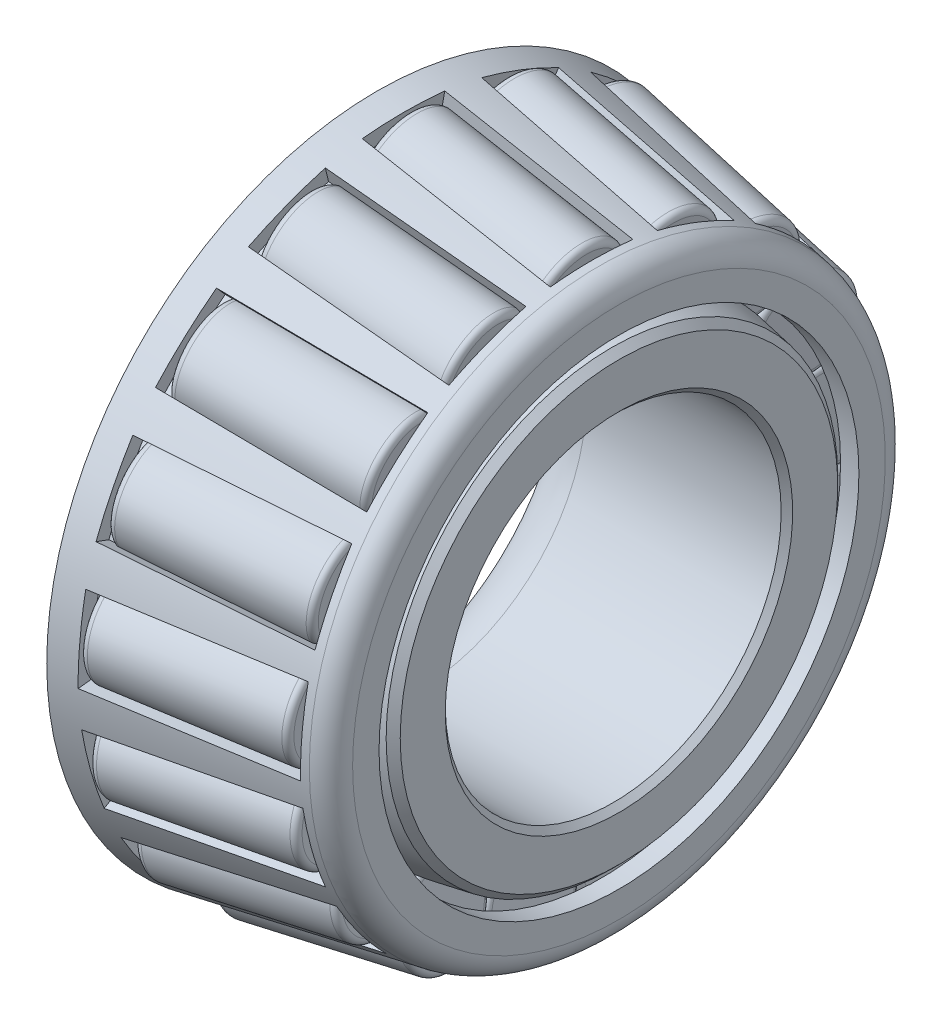
from build123d import *
from OCP.BRepFilletAPI import BRepFilletAPI_MakeChamfer

# Parameters (mm, degrees)
EXTRUDE2_DEPTH    = 2.7305
CIRPATTERN1_COUNT = 17
FILLET1_R         = 0.4064
CIRPATTERN2_COUNT = 17
CHAMFER1_SIZE     = 0.381
CHAMFER1_SIZE2    = 0.473301055
CHAMFER1_SIZE2_2  = 0.327669961


with BuildPart() as part:
    # Sketch1 → Revolve1 (revolve)
    with BuildSketch(Plane.XY):
        with BuildLine():
            Line((-1.651, 21.856453394), (13.047480633, 19.18400237))
            ThreePointArc((13.047480633, 19.18400237), (13.982305872, 18.639295448), (14.351, 17.622108888))
            Line((14.351, 17.622108888), (14.351, 15.875))
            Line((14.351, 15.875), (13.137628204, 15.875))
            Line((13.137628204, 15.875), (13.137628204, 17.625667396))
            ThreePointArc((13.137628204, 17.625667396), (13.04619206, 17.877929663), (12.814355401, 18.01301698))
            Line((12.814355401, 18.01301698), (-1.651, 20.643081598))
            Line((-1.651, 20.643081598), (-1.651, 21.856453394))
        make_face()
    revolve(axis=Axis((0, 0, 0), (1, 0, 0)))

    # Sketch2 → Extrude2 (cut, symmetric)
    with BuildSketch(Plane.XY):
        Polygon((0.786251435, 25.156697843), (13.231418702, 22.893940158), (12.09549617, 16.646366229), (-0.349671097, 18.909123914), align=None)
    extrude2 = extrude(amount=EXTRUDE2_DEPTH, both=True, mode=Mode.SUBTRACT)

    # CirPattern1: Extrude2 ×17 about axis
    cirpattern1_axis = Axis((-1.651, 0, 0), (1, 0, 0))
    for i in range(1, CIRPATTERN1_COUNT):
        add(extrude2.rotate(cirpattern1_axis, i * 360 / CIRPATTERN1_COUNT), mode=Mode.SUBTRACT)


with BuildPart() as body_2:
    # Sketch1_5 → Revolve2 (revolve)
    with BuildSketch(Plane.XY):
        with BuildLine():
            Line((14.351, 14.853227273), (-2.794, 17.9705))
            Line((-2.794, 17.9705), (-2.794, 14.986))
            ThreePointArc((-2.794, 14.986), (-1.659478117, 12.247021883), (1.0795, 11.1125))
            Line((1.0795, 11.1125), (14.351, 11.1125))
            Line((14.351, 11.1125), (14.351, 14.853227273))
        make_face()
    revolve(axis=Axis((0, 0, 0), (1, 0, 0)))


with BuildPart() as body_3:
    # Sketch3 → Revolve3 (revolve)
    with BuildSketch(Plane.XY):
        Polygon((0.025183339, 18.840968562), (11.720641734, 16.714521581), (12.288603, 19.838308545), (0.593144605, 21.964755526), align=None)
    revolve(axis=Axis((0.025183339, 18.840968562, 0), (0.9838699100999075, -0.17888543819998284, 0)))

    # Fillet1
    fillet1_edges = [body_3.edges().sort_by_distance(p)[0] for p in [
        (11.152680468, 13.590734616, 0),
        (-0.542777928, 15.717181597, 0),
    ]]
    fillet(fillet1_edges, radius=FILLET1_R)


with BuildPart() as cirpattern2_1:
    # CirPattern2: pattern copy
    add(body_3.part.rotate(Axis((0, 0, 0), (-1, 0, 0)), 1 * 360 / CIRPATTERN2_COUNT))


with BuildPart() as cirpattern2_2:
    # CirPattern2: pattern copy
    add(body_3.part.rotate(Axis((0, 0, 0), (-1, 0, 0)), 2 * 360 / CIRPATTERN2_COUNT))


with BuildPart() as cirpattern2_3:
    # CirPattern2: pattern copy
    add(body_3.part.rotate(Axis((0, 0, 0), (-1, 0, 0)), 3 * 360 / CIRPATTERN2_COUNT))


with BuildPart() as cirpattern2_4:
    # CirPattern2: pattern copy
    add(body_3.part.rotate(Axis((0, 0, 0), (-1, 0, 0)), 4 * 360 / CIRPATTERN2_COUNT))


with BuildPart() as cirpattern2_5:
    # CirPattern2: pattern copy
    add(body_3.part.rotate(Axis((0, 0, 0), (-1, 0, 0)), 5 * 360 / CIRPATTERN2_COUNT))


with BuildPart() as cirpattern2_6:
    # CirPattern2: pattern copy
    add(body_3.part.rotate(Axis((0, 0, 0), (-1, 0, 0)), 6 * 360 / CIRPATTERN2_COUNT))


with BuildPart() as cirpattern2_7:
    # CirPattern2: pattern copy
    add(body_3.part.rotate(Axis((0, 0, 0), (-1, 0, 0)), 7 * 360 / CIRPATTERN2_COUNT))


with BuildPart() as cirpattern2_8:
    # CirPattern2: pattern copy
    add(body_3.part.rotate(Axis((0, 0, 0), (-1, 0, 0)), 8 * 360 / CIRPATTERN2_COUNT))


with BuildPart() as cirpattern2_9:
    # CirPattern2: pattern copy
    add(body_3.part.rotate(Axis((0, 0, 0), (-1, 0, 0)), 9 * 360 / CIRPATTERN2_COUNT))


with BuildPart() as cirpattern2_10:
    # CirPattern2: pattern copy
    add(body_3.part.rotate(Axis((0, 0, 0), (-1, 0, 0)), 10 * 360 / CIRPATTERN2_COUNT))


with BuildPart() as cirpattern2_11:
    # CirPattern2: pattern copy
    add(body_3.part.rotate(Axis((0, 0, 0), (-1, 0, 0)), 11 * 360 / CIRPATTERN2_COUNT))


with BuildPart() as cirpattern2_12:
    # CirPattern2: pattern copy
    add(body_3.part.rotate(Axis((0, 0, 0), (-1, 0, 0)), 12 * 360 / CIRPATTERN2_COUNT))


with BuildPart() as cirpattern2_13:
    # CirPattern2: pattern copy
    add(body_3.part.rotate(Axis((0, 0, 0), (-1, 0, 0)), 13 * 360 / CIRPATTERN2_COUNT))


with BuildPart() as cirpattern2_14:
    # CirPattern2: pattern copy
    add(body_3.part.rotate(Axis((0, 0, 0), (-1, 0, 0)), 14 * 360 / CIRPATTERN2_COUNT))


with BuildPart() as cirpattern2_15:
    # CirPattern2: pattern copy
    add(body_3.part.rotate(Axis((0, 0, 0), (-1, 0, 0)), 15 * 360 / CIRPATTERN2_COUNT))


with BuildPart() as cirpattern2_16:
    # CirPattern2: pattern copy
    add(body_3.part.rotate(Axis((0, 0, 0), (-1, 0, 0)), 16 * 360 / CIRPATTERN2_COUNT))


with BuildPart() as part_1:
    add(part.part)

    # Combine1: union body 2, body 3, CirPattern2_1, CirPattern2_2, CirPattern2_3, CirPattern2_4, CirPattern2_5, CirPattern2_6, CirPattern2_7, CirPattern2_8, CirPattern2_9, CirPattern2_10, CirPattern2_11, CirPattern2_12, CirPattern2_13, CirPattern2_14, CirPattern2_15, CirPattern2_16
    add(body_2.part)
    add(body_3.part)
    add(cirpattern2_1.part)
    add(cirpattern2_2.part)
    add(cirpattern2_3.part)
    add(cirpattern2_4.part)
    add(cirpattern2_5.part)
    add(cirpattern2_6.part)
    add(cirpattern2_7.part)
    add(cirpattern2_8.part)
    add(cirpattern2_9.part)
    add(cirpattern2_10.part)
    add(cirpattern2_11.part)
    add(cirpattern2_12.part)
    add(cirpattern2_13.part)
    add(cirpattern2_14.part)
    add(cirpattern2_15.part)
    add(cirpattern2_16.part)

    # Chamfer1: one chamfer whose edges measure the first distance from different faces: ONE call of the kernel's chamfer builder (chamfer() names one face for all edges)
    chamfer1_edges_1 = [part_1.edges().sort_by_distance(p)[0] for p in [
        (14.351, -14.853227273, 0),
    ]]
    chamfer1_side_1 = [part_1.faces().sort_by_distance(p)[0] for p in [
        (14.351, -11.532612709, 0),
    ]]
    chamfer1_edges_2 = [part_1.edges().sort_by_distance(p)[0] for p in [
        (-2.794, -17.9705, 0),
    ]]
    chamfer1_side_2 = [part_1.faces().sort_by_distance(p)[0] for p in [
        (5.7785, -16.411863636, 0),
    ]]
    chamfer1_edges_3 = [part_1.edges().sort_by_distance(p)[0] for p in [
        (14.351, -11.1125, 0),
    ]]
    chamfer1 = BRepFilletAPI_MakeChamfer(part_1.part.solid().wrapped)
    for e in chamfer1_edges_1:
        chamfer1.Add(CHAMFER1_SIZE, CHAMFER1_SIZE2, e.wrapped, chamfer1_side_1[0].wrapped)  # the first distance lies on this face
    for e in chamfer1_edges_2:
        chamfer1.Add(CHAMFER1_SIZE, CHAMFER1_SIZE2_2, e.wrapped, chamfer1_side_2[0].wrapped)  # the first distance lies on this face
    for e in chamfer1_edges_3:
        chamfer1.Add(CHAMFER1_SIZE, e.wrapped)
    add(Compound.cast(chamfer1.Shape()), mode=Mode.REPLACE)


solid = part_1.part
